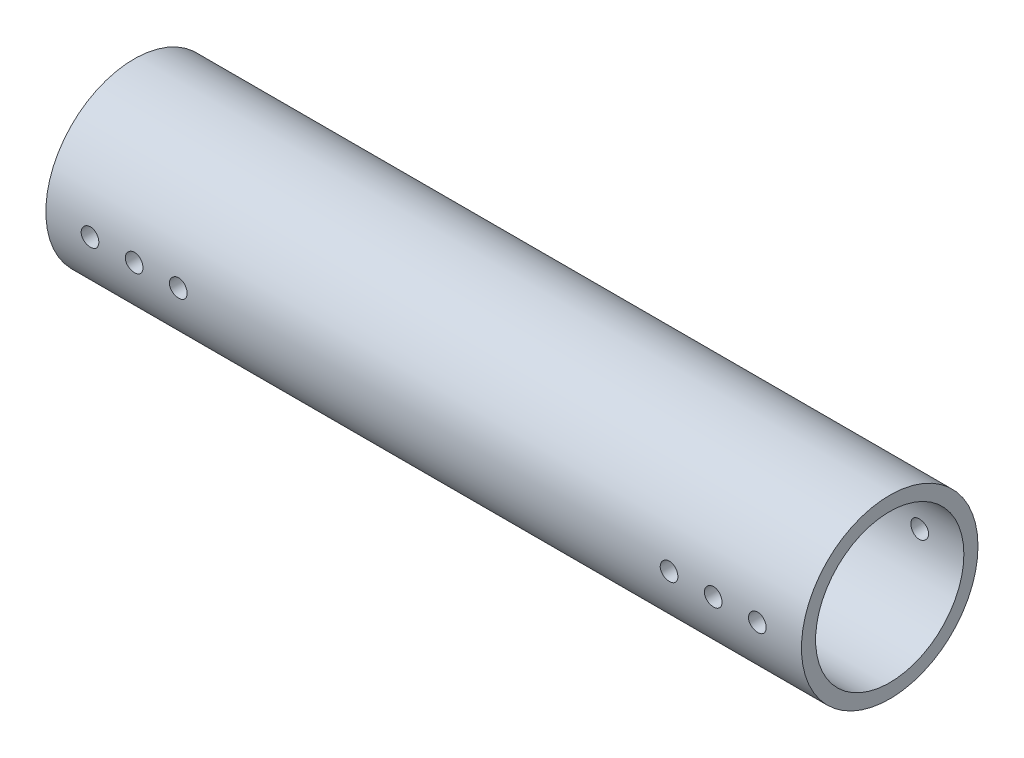
from build123d import *

# Parameters (mm, degrees)
SKETCH_2_R               = 25
SKETCH_2_R_2             = 21
EXTRUDE_2_DEPTH          = 214
CUT_EXTRUDE_2_DEPTH      = 10
CUT_EXTRUDE_2_DEPTH_BACK = 222.18092142
SKETCH_4_R               = 2.5


with BuildPart() as part:
    # Эскиз2 → Бобышка-Вытянуть2 (new body)
    with BuildSketch(Plane(origin=(0, 0, 0), x_dir=(0, 0, -1), z_dir=(1, 0, 0))):
        Circle(SKETCH_2_R)
        Circle(SKETCH_2_R_2, mode=Mode.SUBTRACT)
    extrude(amount=EXTRUDE_2_DEPTH)

    # Эскиз4 → Вырез-Вытянуть2 (cut, two sides: drawn at the far end of the back side and taken through both)
    with BuildSketch(Plane.XY.offset(25).offset(-CUT_EXTRUDE_2_DEPTH_BACK)):
        with Locations((12.5, 0)):
            Circle(SKETCH_4_R)
        with Locations((201.5, 0)):
            Circle(SKETCH_4_R)
        with Locations((25, 0)):
            Circle(SKETCH_4_R)
        with Locations((37.5, 0)):
            Circle(SKETCH_4_R)
        with Locations((189, 0)):
            Circle(SKETCH_4_R)
        with Locations((176.5, 0)):
            Circle(SKETCH_4_R)
    extrude(amount=CUT_EXTRUDE_2_DEPTH + CUT_EXTRUDE_2_DEPTH_BACK, mode=Mode.SUBTRACT)


solid = part.part
